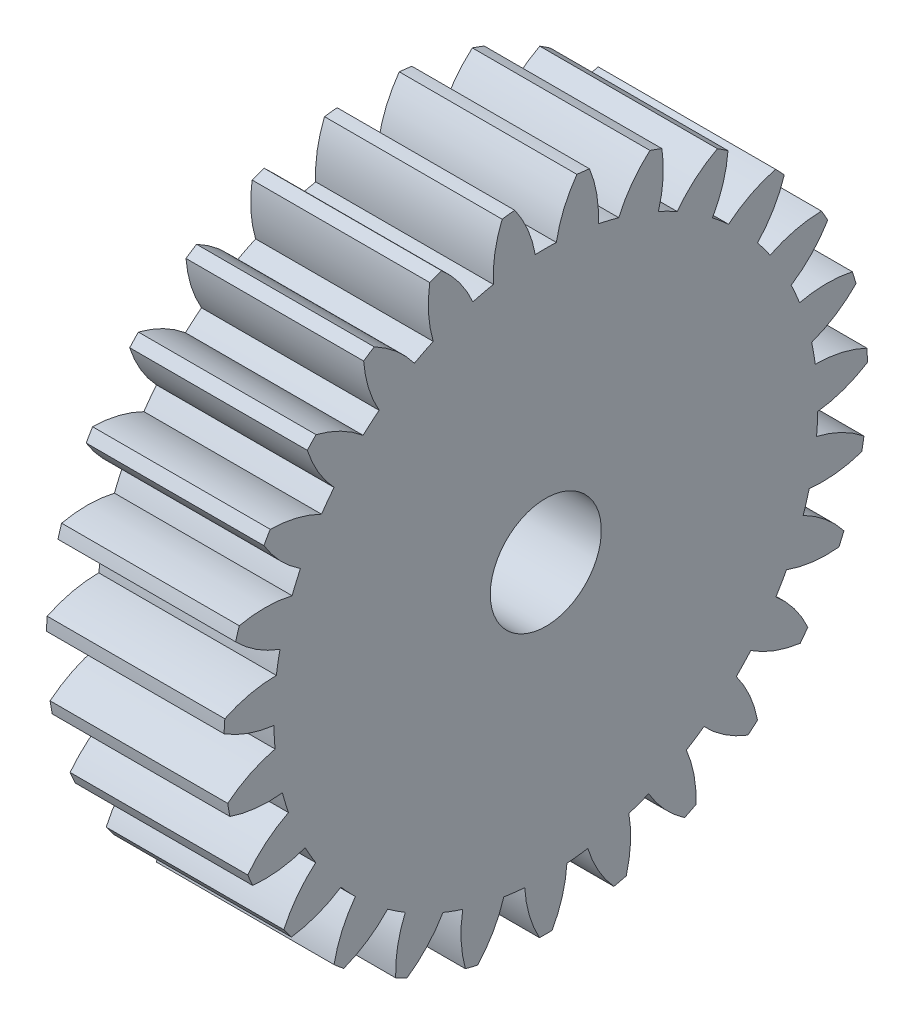
from build123d import *

# Parameters (mm, degrees)
BASPROSKE_W     = 8
BASPROSKE_H     = 14.5
TOOTHCUT_DEPTH  = 23.011360703
TEETHCUTS_COUNT = 27
TEETHCUTS_ANGLE = 346.666666667
BORSKE_R        = 2.5
BORE_DEPTH      = 50.0000508


with BuildPart() as part:
    # BasProSke → Base-Revolve (revolve)
    with BuildSketch(Plane(origin=(0, 0, 0), x_dir=(1, 0, 0), z_dir=(0, 1, 0)), mode=Mode.PRIVATE) as base_revolve_sk:
        with Locations((4, 7.25)):
            Rectangle(BASPROSKE_W, BASPROSKE_H)
    revolve(base_revolve_sk.sketch.rotate(Axis((-10, 0, 0), (1, 0, 0)), 180), axis=Axis((-10, 0, 0), (1, 0, 0)))

    # TooCutSke → ToothCut (cut, through all)
    with BuildSketch(Plane(origin=(0, 0, 0), x_dir=(0, 0, -1), z_dir=(1, 0, 0))):
        with BuildLine():
            ThreePointArc((0.474054864, 12.239823242), (0, 12.249), (-0.474054864, 12.239823242))
            ThreePointArc((-0.474054864, 12.239823242), (-0.820231692, 13.40120918), (-1.416685779, 14.456149092))
            ThreePointArc((-1.416685779, 14.456149092), (0, 14.5254), (1.416685779, 14.456149092))
            ThreePointArc((1.416685779, 14.456149092), (0.820231692, 13.40120918), (0.474054864, 12.239823242))
        make_face()
    toothcut = extrude(amount=TOOTHCUT_DEPTH, mode=Mode.SUBTRACT)

    # TeethCuts: ToothCut ×27 about axis
    teethcuts_axis = Axis((-10, 0, 0), (1, 0, 0))
    for i in range(1, TEETHCUTS_COUNT):
        add(toothcut.rotate(teethcuts_axis, i * TEETHCUTS_ANGLE / (TEETHCUTS_COUNT - 1)), mode=Mode.SUBTRACT)

    # BorSke → Bore (cut, symmetric)
    with BuildSketch(Plane(origin=(0, 0, 0), x_dir=(0, 0, -1), z_dir=(1, 0, 0))):
        with Locations(Location((0, 0, 0), (0, 0, 180))):
            Circle(BORSKE_R)
    extrude(amount=BORE_DEPTH, both=True, mode=Mode.SUBTRACT)


solid = part.part
